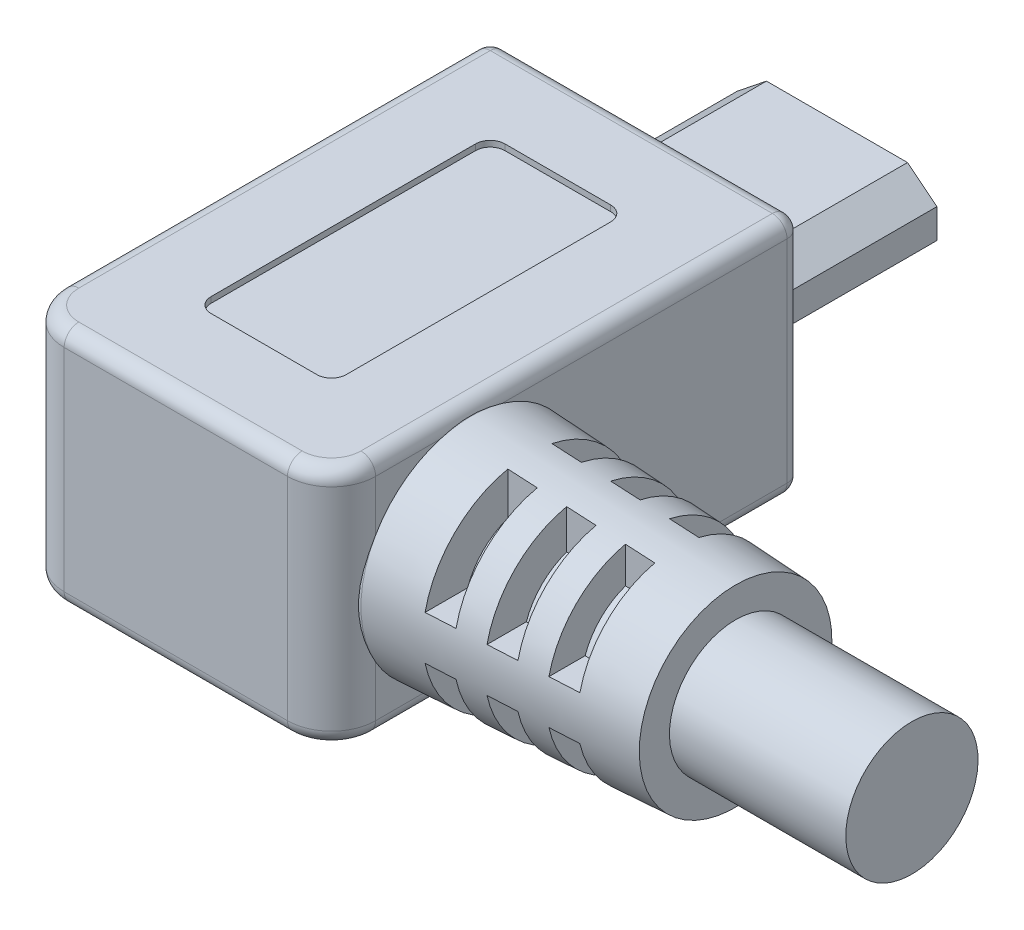
from build123d import *

# Parameters (mm, degrees)
SKETCH1_W                     = 3.7
SKETCH1_H                     = 0.65
BOSS_EXTRUDE1_DEPTH           = 6.5
SKETCH2_W                     = 10.6
SKETCH2_H                     = 8.2
BOSS_EXTRUDE2_DEPTH           = 16
SKETCH6_W                     = 4.6
SKETCH6_H                     = 10
CUT_EXTRUDE2_DEPTH            = 0.2
FILLET3_R                     = 0.5
FILLET3_OF_MIRROR2_R          = 0.5
FILLET1_R                     = 1.5
FILLET2_R                     = 0.5
SKETCH3_R                     = 3.75
BOSS_EXTRUDE3_DEPTH           = 9
BOSS_EXTRUDE3_TAPER           = 3
BOSS_EXTRUDE3_OTHER_WAY_DEPTH = 8.7
SKETCH5_W                     = 1
SKETCH5_H                     = 2.895184441
CUT_EXTRUDE1_DEPTH            = 3.35
SKETCH4_R                     = 2.25
BOSS_EXTRUDE4_DEPTH           = 15


with BuildPart() as part:
    # Sketch1 → Boss-Extrude1 (new body)
    with BuildSketch(Plane.XY):
        Polygon((1, 1.8), (0, 1), (0, 0), (6.8, 0), (6.8, 1), (5.8, 1.8), align=None)
        with Locations((3.4, 0.525)):
            Rectangle(SKETCH1_W, SKETCH1_H, mode=Mode.SUBTRACT)
    extrude(amount=BOSS_EXTRUDE1_DEPTH)

    # Sketch2 → Boss-Extrude2 (add)
    with BuildSketch(Plane.XY.offset(6.5)):
        with Locations((3.4, 0.9)):
            Rectangle(SKETCH2_W, SKETCH2_H)
    extrude(amount=BOSS_EXTRUDE2_DEPTH)

    # Sketch6 → Cut-Extrude2 (cut)
    with BuildSketch(Plane(origin=(0, 5, 0), x_dir=(1, 0, 0), z_dir=(0, 1, 0))):
        with Locations((3.4, -14.5)):
            Rectangle(SKETCH6_W, SKETCH6_H)
    cut_extrude2 = extrude(amount=-CUT_EXTRUDE2_DEPTH, mode=Mode.SUBTRACT)

    # Fillet3
    fillet3_edges = [part.edges().sort_by_distance(p)[0] for p in [
        (5.7, 4.9, 9.5),
        (5.7, 4.9, 19.5),
        (1.1, 4.9, 19.5),
        (1.1, 4.9, 9.5),
    ]]
    fillet(fillet3_edges, radius=FILLET3_R)

    # Mirror2: Cut-Extrude2 across plane
    add(cut_extrude2.mirror(Plane.ZX.offset(0.9)), mode=Mode.SUBTRACT)

    # Fillet3 of Mirror2
    fillet3_of_mirror2_edges = [part.edges().sort_by_distance(p)[0] for p in [
        (5.7, -3.1, 9.5),
        (5.7, -3.1, 19.5),
        (1.1, -3.1, 19.5),
        (1.1, -3.1, 9.5),
    ]]
    fillet(fillet3_of_mirror2_edges, radius=FILLET3_OF_MIRROR2_R)

    # Fillet1
    fillet1_edges = [part.edges().sort_by_distance(p)[0] for p in [
        (8.7, 0.9, 22.5),
        (-1.9, 0.9, 22.5),
    ]]
    fillet(fillet1_edges, radius=FILLET1_R)

    # Fillet2
    fillet2_edges = [part.edges().sort_by_distance(p)[0] for p in [
        (3.4, 5, 22.5),
        (3.4, -3.2, 22.5),
        (8.7, -3.2, 13.75),
        (-1.9, -3.2, 13.75),
        (8.260660172, -3.2, 22.060660172),
        (-1.460660172, -3.2, 22.060660172),
        (-1.9, 5, 13.75),
        (8.7, 5, 13.75),
        (8.260660172, 5, 22.060660172),
        (-1.460660172, 5, 22.060660172),
        (8.7, 0.9, 6.5),
        (3.4, 5, 6.5),
        (-1.9, 0.9, 6.5),
        (3.4, -3.2, 6.5),
    ]]
    fillet(fillet2_edges, radius=FILLET2_R)

    # Sketch3 → Boss-Extrude3 (add)
    with BuildSketch(Plane(origin=(8.7, 0, 0), x_dir=(0, 0, -1), z_dir=(1, 0, 0))):
        with Locations((-17.75, 0.9)):
            Circle(SKETCH3_R)
    extrude(amount=BOSS_EXTRUDE3_DEPTH, taper=BOSS_EXTRUDE3_TAPER)

    # Sketch3 → Boss-Extrude3 other way (add)
    with BuildSketch(Plane(origin=(8.7, 0, 0), x_dir=(0, 0, -1), z_dir=(1, 0, 0))):
        with Locations((-17.75, 0.9)):
            Circle(SKETCH3_R)
    extrude(amount=-BOSS_EXTRUDE3_OTHER_WAY_DEPTH)

    # Sketch5 → Cut-Extrude1 (cut)
    with BuildSketch(Plane(origin=(0, 5, 0), x_dir=(1, 0, 0), z_dir=(0, 1, 0))):
        with Locations((11.2, -15.55240778)):
            Rectangle(SKETCH5_W, SKETCH5_H)
        with Locations((13.2, -15.55240778)):
            Rectangle(SKETCH5_W, SKETCH5_H)
        with Locations((15.2, -15.55240778)):
            Rectangle(SKETCH5_W, SKETCH5_H)
        with Locations((11.2, -19.94759222)):
            Rectangle(SKETCH5_W, SKETCH5_H)
        with Locations((13.2, -19.94759222)):
            Rectangle(SKETCH5_W, SKETCH5_H)
        with Locations((15.2, -19.94759222)):
            Rectangle(SKETCH5_W, SKETCH5_H)
    cut_extrude1 = extrude(amount=-CUT_EXTRUDE1_DEPTH, mode=Mode.SUBTRACT)

    # Mirror1: Cut-Extrude1 across plane
    add(cut_extrude1.mirror(Plane.ZX.offset(0.9)), mode=Mode.SUBTRACT)

    # Sketch4 → Boss-Extrude4 (add)
    with BuildSketch(Plane(origin=(8.7, 0, 0), x_dir=(0, 0, -1), z_dir=(1, 0, 0))):
        with Locations((-17.75, 0.9)):
            Circle(SKETCH4_R)
    extrude(amount=BOSS_EXTRUDE4_DEPTH)


solid = part.part
